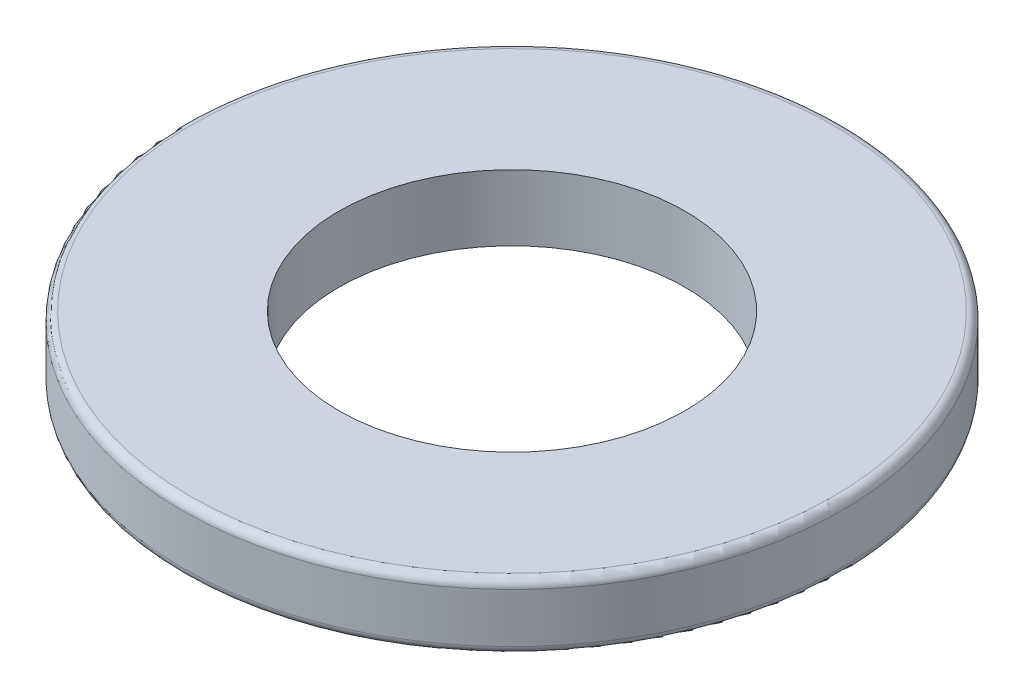
from build123d import *

# Parameters (mm, degrees)
SZKIC1_R                    = 8
SZKIC1_R_2                  = 4.2
DODANIE_WYCI_GNI_CIE1_DEPTH = 1.6
ZAOKR_GLENIE1_R             = 0.2


with BuildPart() as part:
    # Szkic1 → Dodanie-wyciągnięcie1 (new body)
    with BuildSketch(Plane(origin=(0, 0, 0), x_dir=(1, 0, 0), z_dir=(0, 1, 0))):
        with Locations((0, 17.002511285)):
            Circle(SZKIC1_R)
        with Locations((0, 17.002511285)):
            Circle(SZKIC1_R_2, mode=Mode.SUBTRACT)
    extrude(amount=DODANIE_WYCI_GNI_CIE1_DEPTH)

    # Zaokrąglenie1
    zaokr_glenie1_edges = [part.edges().sort_by_distance(p)[0] for p in [
        (-8, 0, -17.002511285),
        (-8, 1.6, -17.002511285),
    ]]
    fillet(zaokr_glenie1_edges, radius=ZAOKR_GLENIE1_R)


solid = part.part
